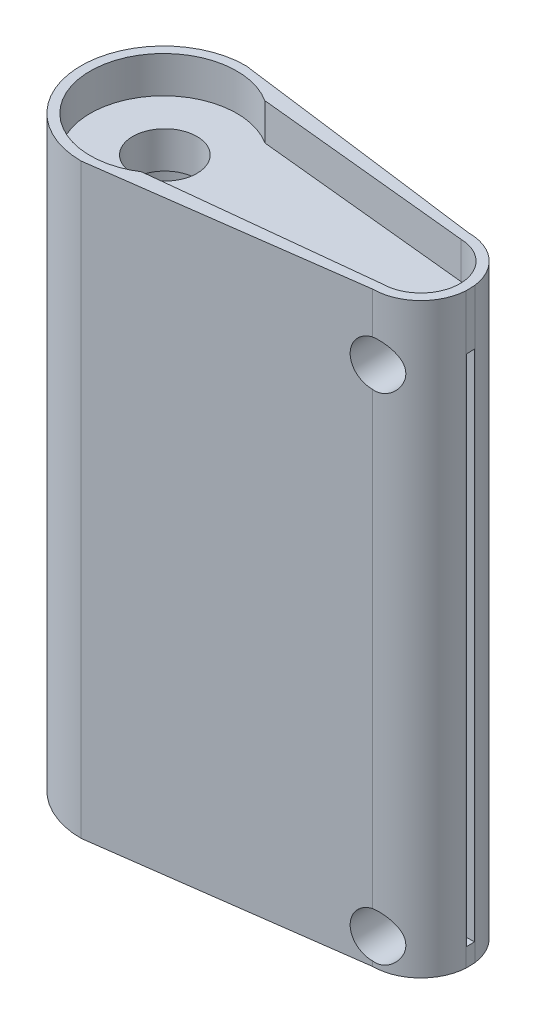
from build123d import *

# Parameters (mm, degrees)
SKETCH2_R           = 1.75
BOSS_EXTRUDE1_DEPTH = 30
BOSS_EXTRUDE2_DEPTH = 32
SKETCH6_R           = 3
CUT_EXTRUDE3_DEPTH  = 28
SKETCH7_W           = 0.45
SKETCH7_H           = 28
CUT_EXTRUDE4_DEPTH  = 13
SKETCH8_R           = 1.25
CUT_EXTRUDE5_DEPTH  = 46.13881934
SKETCH8_3_R         = 1.25
CUT_EXTRUDE6_DEPTH  = 46.138819411


with BuildPart() as part:
    # Sketch2 → Boss-Extrude1 (new body)
    with BuildSketch(Plane(origin=(0, 0, 0), x_dir=(1, 0, 0), z_dir=(0, 1, 0))):
        with BuildLine():
            Line((-24.821747911, -3.435069212), (-12.987160246, -2.166440487))
            ThreePointArc((-12.987160246, -2.166440487), (-10.8566751, -0.059524017), (-12.939762178, 2.094266176))
            Line((-12.939762178, 2.094266176), (-24.821781773, 3.29179515))
            ThreePointArc((-24.821781773, 3.29179515), (-30.987291256, -0.071668068), (-24.821747911, -3.435069212))
        make_face()
        with Locations((-26.987114413, 0)):
            Circle(SKETCH2_R, mode=Mode.SUBTRACT)
    extrude(amount=BOSS_EXTRUDE1_DEPTH)

    # Sketch2_3 → Boss-Extrude2 (add)
    with BuildSketch(Plane(origin=(0, 0, 0), x_dir=(1, 0, 0), z_dir=(0, 1, 0))):
        with BuildLine():
            ThreePointArc((-26.987114411, 4.428185187), (-31.48694753, -0.071647931), (-26.987114411, -4.57148105))
            Line((-26.987114411, -4.57148105), (-12.987160246, -2.67247066))
            ThreePointArc((-12.987160246, -2.67247066), (-11.181747177, -1.957383249), (-10.355629468, -0.2))
            Line((-10.355629468, -0.2), (-10.371987074, 0.3))
            ThreePointArc((-10.371987074, 0.3), (-11.245543176, 1.943741621), (-12.987160246, 2.600823626))
            Line((-12.987160246, 2.600823626), (-26.987114411, 4.428185187))
        make_face()
        with BuildLine():
            Line((-24.821781773, 3.29179515), (-12.939762178, 2.094266176))
            ThreePointArc((-12.939762178, 2.094266176), (-10.8566751, -0.059524017), (-12.987160246, -2.166440487))
            Line((-12.987160246, -2.166440487), (-24.821747911, -3.435069212))
            ThreePointArc((-24.821747911, -3.435069212), (-30.987291256, -0.071668068), (-24.821781773, 3.29179515))
        make_face(mode=Mode.SUBTRACT)
    extrude(amount=BOSS_EXTRUDE2_DEPTH)

    # Sketch6 → Cut-Extrude3 (cut)
    with BuildSketch(Plane.XZ):
        with Locations((-26.987114413, 0)):
            Circle(SKETCH6_R)
    extrude(amount=-CUT_EXTRUDE3_DEPTH, mode=Mode.SUBTRACT)

    # Sketch7 → Cut-Extrude4 (cut)
    with BuildSketch(Plane(origin=(-10.351093889, 0, 0.338638235), x_dir=(-0.03269771907792212, 0, -0.9994652866243537), z_dir=(0.9994652866243537, 0, -0.03269771907792212))):
        with Locations((0.388846156, 15)):
            Rectangle(SKETCH7_W, SKETCH7_H)
    extrude(amount=-CUT_EXTRUDE4_DEPTH, mode=Mode.SUBTRACT)

    # Sketch8 → Cut-Extrude5 (cut, through all)
    with BuildSketch(Plane(origin=(-0.005357396, 0, -0.163758545), x_dir=(-0.9994652866243537, 0, 0.03269771907792212), z_dir=(-0.03269771907792212, 0, -0.9994652866243537))):
        with Locations((12.895174838, 28.5)):
            Circle(SKETCH8_R)
        with Locations((12.895174838, 1.5)):
            Circle(SKETCH8_R)
    extrude(amount=-CUT_EXTRUDE5_DEPTH, mode=Mode.SUBTRACT)

    # Sketch8_3 → Cut-Extrude6 (cut, through all)
    with BuildSketch(Plane(origin=(-0.005357396, 0, -0.163758545), x_dir=(-0.9994652866243537, 0, 0.03269771907792212), z_dir=(-0.03269771907792212, 0, -0.9994652866243537))):
        with Locations((12.895174838, 28.5)):
            Circle(SKETCH8_3_R)
        with Locations((12.895174838, 1.5)):
            Circle(SKETCH8_3_R)
    extrude(amount=CUT_EXTRUDE6_DEPTH, mode=Mode.SUBTRACT)


solid = part.part
